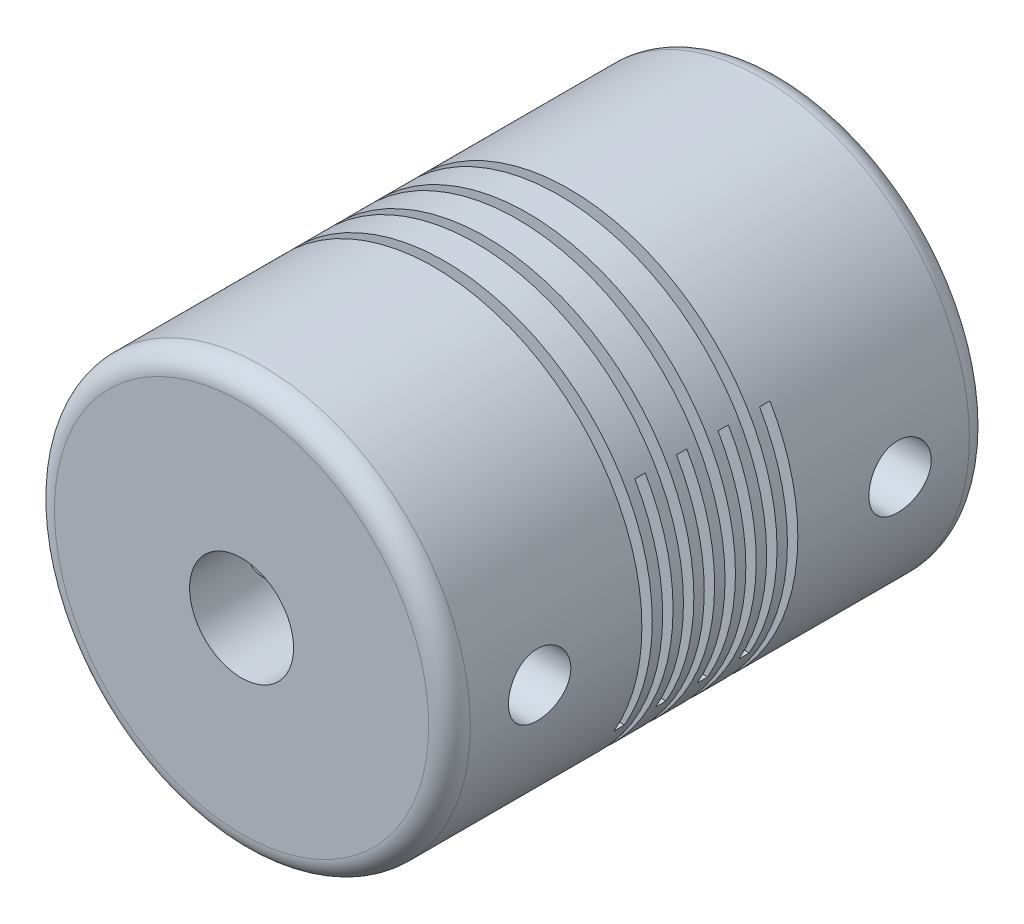
from build123d import *

# Parameters (mm, degrees)
SKETCH_1_R               = 10
SKETCH_1_R_2             = 2.5
EXTRUDE_1_DEPTH          = 26
SKETCH_2_R               = 1.5
SKETCH_2_W               = 0.5
SKETCH_2_H               = 15
CUT_EXTRUDE_1_DEPTH      = 11
CUT_EXTRUDE_1_DEPTH_BACK = 11
SKETCH_3_R               = 3
CUT_EXTRUDE_2_DEPTH      = 9.25
FILLET_1_R               = 1


with BuildPart() as part:
    # Эскиз1 → Бобышка-Вытянуть1 (new body)
    with BuildSketch(Plane.XY):
        Circle(SKETCH_1_R)
        Circle(SKETCH_1_R_2, mode=Mode.SUBTRACT)
    extrude(amount=-EXTRUDE_1_DEPTH)

    # Эскиз2 → Вырез-Вытянуть1 (cut, two sides)
    with BuildSketch(Plane(origin=(0, 0, 0), x_dir=(0, 0, -1), z_dir=(1, 0, 0))) as cut_extrude_1_sk:
        with Locations((4.333333333, 0)):
            Circle(SKETCH_2_R)
        with Locations((21.666666667, 0)):
            Circle(SKETCH_2_R)
        with Locations((13.5, 2.5)):
            Rectangle(SKETCH_2_W, SKETCH_2_H)
        with Locations((15.5, 2.5)):
            Rectangle(SKETCH_2_W, SKETCH_2_H)
        with Locations((14.5, -2.5)):
            Rectangle(SKETCH_2_W, SKETCH_2_H)
        with Locations((16.5, -2.5)):
            Rectangle(SKETCH_2_W, SKETCH_2_H)
        with Locations((11.5, 2.5)):
            Rectangle(SKETCH_2_W, SKETCH_2_H)
        with Locations((12.5, -2.5)):
            Rectangle(SKETCH_2_W, SKETCH_2_H)
        with Locations((9.5, 2.5)):
            Rectangle(SKETCH_2_W, SKETCH_2_H)
        with Locations((10.5, -2.5)):
            Rectangle(SKETCH_2_W, SKETCH_2_H)
    extrude(amount=CUT_EXTRUDE_1_DEPTH, mode=Mode.SUBTRACT)
    extrude(cut_extrude_1_sk.sketch, amount=-CUT_EXTRUDE_1_DEPTH_BACK, mode=Mode.SUBTRACT)

    # Эскиз3 → Вырез-Вытянуть2 (cut)
    with BuildSketch(Plane(origin=(0, 0, -26), x_dir=(-1, 0, 0), z_dir=(0, 0, -1))):
        Circle(SKETCH_3_R)
    extrude(amount=-CUT_EXTRUDE_2_DEPTH, mode=Mode.SUBTRACT)

    # Скругление1
    fillet_1_edges = [part.edges().sort_by_distance(p)[0] for p in [
        (-10, 0, 0),
        (-10, 0, -26),
    ]]
    fillet(fillet_1_edges, radius=FILLET_1_R)


solid = part.part
